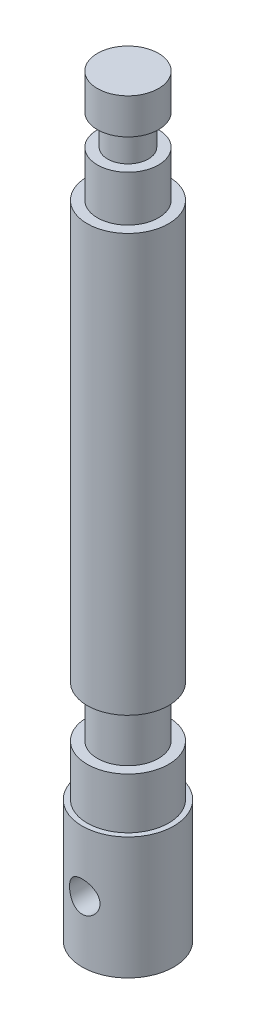
from build123d import *

# Parameters (mm, degrees)
SKETCH1_R               = 9
BOSS_EXTRUDE1_DEPTH     = 24
SKETCH2_R               = 8
BOSS_EXTRUDE2_DEPTH     = 10
SKETCH3_R               = 6
BOSS_EXTRUDE3_DEPTH     = 10
SKETCH4_R               = 8
BOSS_EXTRUDE4_DEPTH     = 82
SKETCH5_R               = 6
BOSS_EXTRUDE5_DEPTH     = 9
SKETCH6_R               = 4
BOSS_EXTRUDE6_DEPTH     = 6
SKETCH7_R               = 6
BOSS_EXTRUDE7_DEPTH     = 7
SKETCH8_R               = 3
CUT_EXTRUDE1_DEPTH      = 10
CUT_EXTRUDE1_DEPTH_BACK = 10


with BuildPart() as part:
    # Sketch1 → Boss-Extrude1 (new body)
    with BuildSketch(Plane(origin=(0, 0, 0), x_dir=(1, 0, 0), z_dir=(0, 1, 0))):
        Circle(SKETCH1_R)
    extrude(amount=BOSS_EXTRUDE1_DEPTH)

    # Sketch2 → Boss-Extrude2 (add)
    with BuildSketch(Plane(origin=(0, 24, 0), x_dir=(1, 0, 0), z_dir=(0, 1, 0))):
        Circle(SKETCH2_R)
    extrude(amount=BOSS_EXTRUDE2_DEPTH)

    # Sketch3 → Boss-Extrude3 (add)
    with BuildSketch(Plane(origin=(0, 34, 0), x_dir=(1, 0, 0), z_dir=(0, 1, 0))):
        Circle(SKETCH3_R)
    extrude(amount=BOSS_EXTRUDE3_DEPTH)

    # Sketch4 → Boss-Extrude4 (add)
    with BuildSketch(Plane(origin=(0, 44, 0), x_dir=(1, 0, 0), z_dir=(0, 1, 0))):
        Circle(SKETCH4_R)
    extrude(amount=BOSS_EXTRUDE4_DEPTH)

    # Sketch5 → Boss-Extrude5 (add)
    with BuildSketch(Plane(origin=(0, 126, 0), x_dir=(1, 0, 0), z_dir=(0, 1, 0))):
        Circle(SKETCH5_R)
    extrude(amount=BOSS_EXTRUDE5_DEPTH)

    # Sketch6 → Boss-Extrude6 (add)
    with BuildSketch(Plane(origin=(0, 135, 0), x_dir=(1, 0, 0), z_dir=(0, 1, 0))):
        Circle(SKETCH6_R)
    extrude(amount=BOSS_EXTRUDE6_DEPTH)

    # Sketch7 → Boss-Extrude7 (add)
    with BuildSketch(Plane(origin=(0, 141, 0), x_dir=(1, 0, 0), z_dir=(0, 1, 0))):
        Circle(SKETCH7_R)
    extrude(amount=BOSS_EXTRUDE7_DEPTH)

    # Sketch8 → Cut-Extrude1 (cut, two sides)
    with BuildSketch(Plane.XY) as cut_extrude1_sk:
        with Locations((0, 12)):
            Circle(SKETCH8_R)
    extrude(amount=CUT_EXTRUDE1_DEPTH, mode=Mode.SUBTRACT)
    extrude(cut_extrude1_sk.sketch, amount=-CUT_EXTRUDE1_DEPTH_BACK, mode=Mode.SUBTRACT)


solid = part.part
